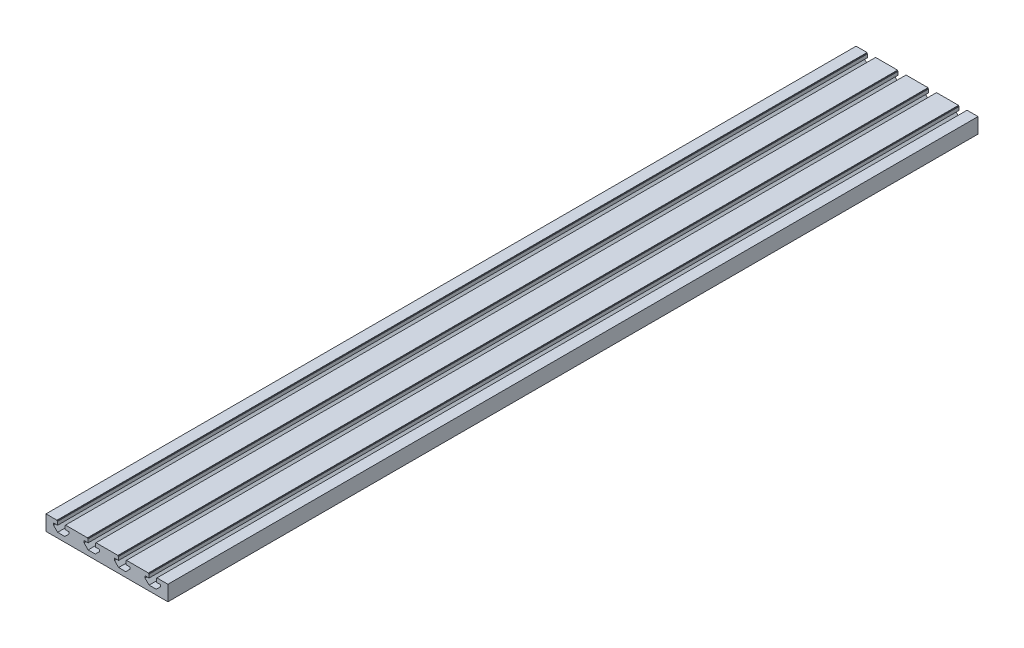
from build123d import *

# Parameters (mm, degrees)
EXTRUDE1_DEPTH  = 1196
LPATTERN2_COUNT = 4
LPATTERN2_PITCH = 45


with BuildPart() as part:
    # Sketch1 → Extrude1 (new body)
    with BuildSketch(Plane.XY):
        Polygon((0, 22.5), (16.2, 22.5), (16.2, 21.5), (17.2, 21.5), (17.2, 16.5), (11.2, 16.5), (11.2, 13.5), (17.2, 7.5), (27.8, 7.5), (33.8, 13.5), (33.8, 16.5), (27.8, 16.5), (27.8, 21.5), (28.8, 21.5), (28.8, 22.5), (45, 22.5), (45, 0), (0, 0), align=None)
    extrude1 = extrude(amount=EXTRUDE1_DEPTH)

    # LPattern2: Extrude1 ×4
    with Locations(*[(i * LPATTERN2_PITCH, 0, 0) for i in range(1, LPATTERN2_COUNT)]):
        add(extrude1)


solid = part.part
